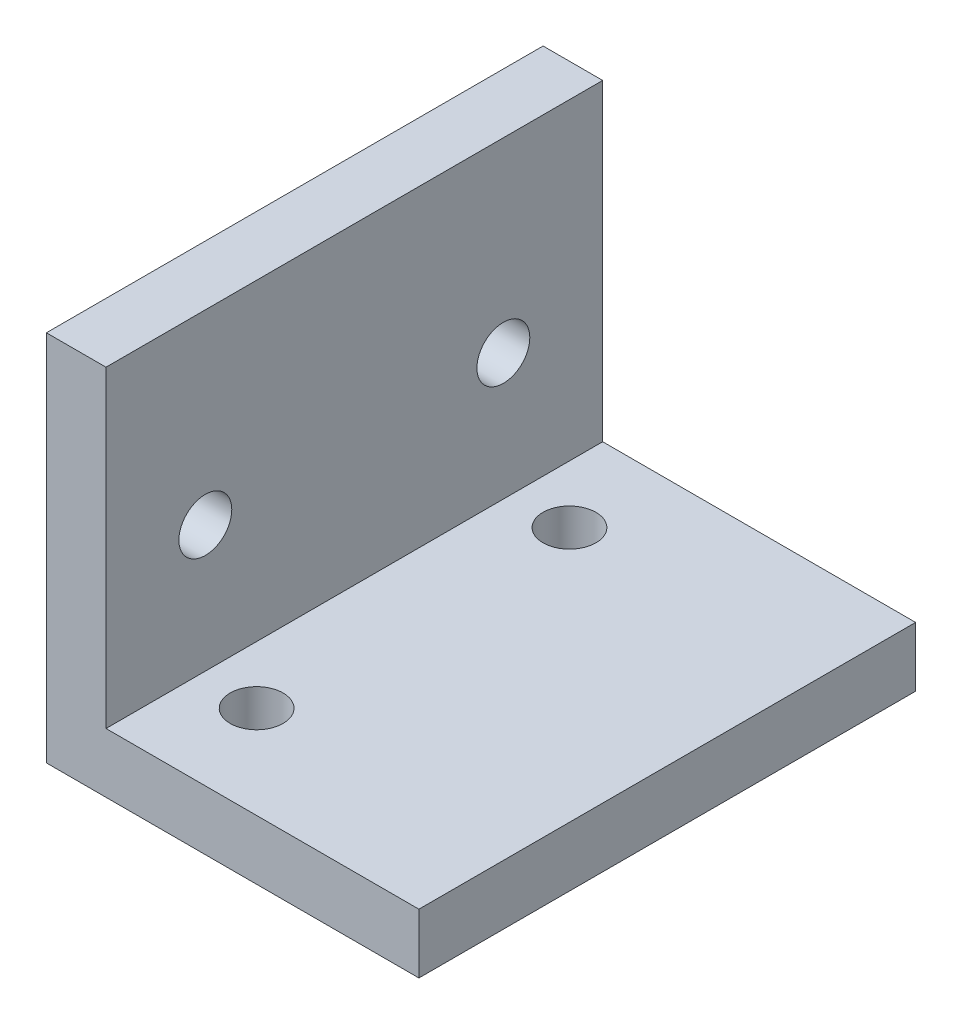
from build123d import *

# Parameters (mm, degrees)
BOSS_EXTRUDE1_DEPTH   = 25.4
F_6_32_TAPPED_HOLE1_D = 2.7051
F_6_32_TAPPED_HOLE2_D = 2.7051


with BuildPart() as part:
    # Sketch1 → Boss-Extrude1 (new body)
    with BuildSketch(Plane.XY):
        Polygon((0, 0), (19.05, 0), (19.05, 3.048), (3.048, 3.048), (3.048, 19.05), (0, 19.05), align=None)
    extrude(amount=BOSS_EXTRUDE1_DEPTH)

    # 6-32 Tapped Hole1 (through all)
    with Locations(Plane(origin=(3.048, 0, 0), x_dir=(0, 0, -1), z_dir=(1, 0, 0))):
        with Locations((-20.32, 9.525), (-5.08, 9.525)):
            Hole(F_6_32_TAPPED_HOLE1_D / 2)

    # 6-32 Tapped Hole2 (through all)
    with Locations(Plane(origin=(0, 3.048, 0), x_dir=(1, 0, 0), z_dir=(0, 1, 0))):
        with Locations((6, -20.65), (6, -4.65)):
            Hole(F_6_32_TAPPED_HOLE2_D / 2)


solid = part.part
